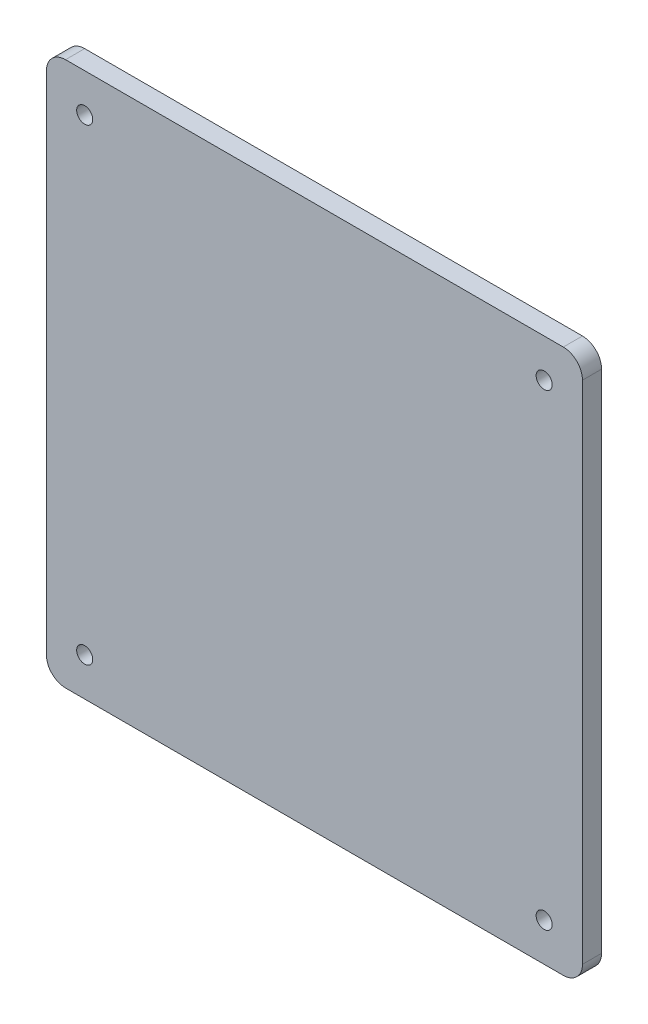
from build123d import *

# Parameters (mm, degrees)
SKETCH_1_W              = 280
SKETCH_1_H              = 284.25
EXTRUDE_1_DEPTH         = 10
FILLET_1_R              = 10
HOLE_WIZARD_8_4_8_4_1_D = 8.4


with BuildPart() as part:
    # 草图1 → 凸台-拉伸1 (new body)
    with BuildSketch(Plane.XY):
        Rectangle(SKETCH_1_W, SKETCH_1_H)
    extrude(amount=EXTRUDE_1_DEPTH)

    # 圆角1
    fillet_1_edges = [part.edges().sort_by_distance(p)[0] for p in [
        (140, -142.125, 5),
        (-140, -142.125, 5),
        (-140, 142.125, 5),
        (140, 142.125, 5),
    ]]
    fillet(fillet_1_edges, radius=FILLET_1_R)

    # Ø8.4 (8.4) 直径孔1 (through all)
    with Locations(Plane(origin=(0, 0, 0), x_dir=(1, 0, 0), z_dir=(0, 0, -1))):
        with Locations((-120, -122.125), (120, -122.125), (120, 122.125), (-120, 122.125)):
            Hole(HOLE_WIZARD_8_4_8_4_1_D / 2)


solid = part.part
